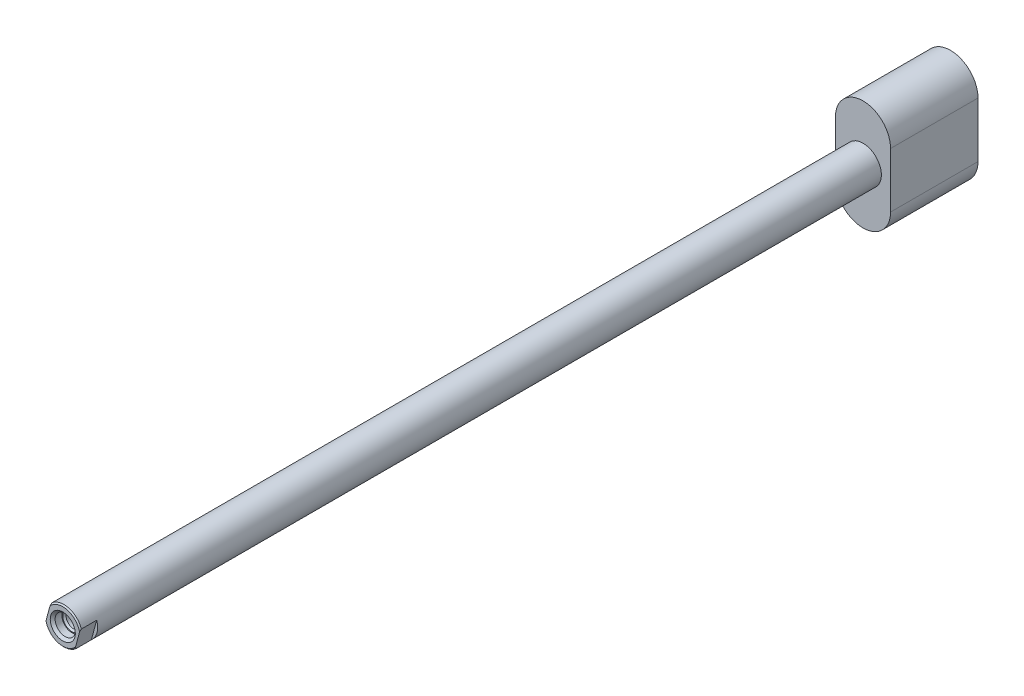
from build123d import *

# Parameters (mm, degrees)
CUT_EXTRUDE1_DEPTH  = 3.3
BOSS_EXTRUDE1_DEPTH = 14.3


with BuildPart() as part:
    # Sketch1 → Revolve1 (revolve)
    with BuildSketch(Plane(origin=(0, 0, 0), x_dir=(0, 0, -1), z_dir=(1, 0, 0))):
        Polygon((-7, 0), (-7, 2.8), (-6.8, 3), (138.15, 3), (138.15, 0), align=None)
    revolve(axis=Axis((0, 0, -138.15), (0, 0, 1)))

    # Sketch2 → Cut-Revolve1 (revolve, cut)
    with BuildSketch(Plane(origin=(0, 0, 0), x_dir=(0, 0, -1), z_dir=(1, 0, 0))):
        Polygon((-7, 0), (-7, 2.05), (-6.6, 1.65), (-5.5, 1.65), (-5.5, 1.5), (-5.2295, 1.2295), (4, 1.2295), (4.709852156, 0), align=None)
    revolve(axis=Axis((0, 0, -4.709852156), (0, 0, 1)), mode=Mode.SUBTRACT)

    # Sketch3 → Cut-Extrude1 (cut)
    with BuildSketch(Plane.XY.offset(4.3)):
        Polygon((-6.447248163, -4.742941189), (3.2120101, -7.33113164), (5.800200551, 2.328126623), (3.385385985, 2.975174236), (1.12071934, -5.476676744), (-3.708909791, -4.182581519), (-1.444243147, 4.269269461), (-3.859057712, 4.916317074), align=None)
    extrude(amount=CUT_EXTRUDE1_DEPTH, mode=Mode.SUBTRACT)

    # Sketch4 → Boss-Extrude1 (add)
    with BuildSketch(Plane.XY.offset(-138.15)):
        with BuildLine():
            Line((4.5, -4.5), (4.5, 4.5))
            ThreePointArc((4.5, 4.5), (3.181980515, 7.681980515), (0, 9))
            ThreePointArc((0, 9), (-3.181980515, 7.681980515), (-4.5, 4.5))
            Line((-4.5, 4.5), (-4.5, -4.5))
            ThreePointArc((-4.5, -4.5), (-3.181980515, -7.681980515), (0, -9))
            ThreePointArc((0, -9), (3.181980515, -7.681980515), (4.5, -4.5))
        make_face()
    extrude(amount=BOSS_EXTRUDE1_DEPTH)


solid = part.part
